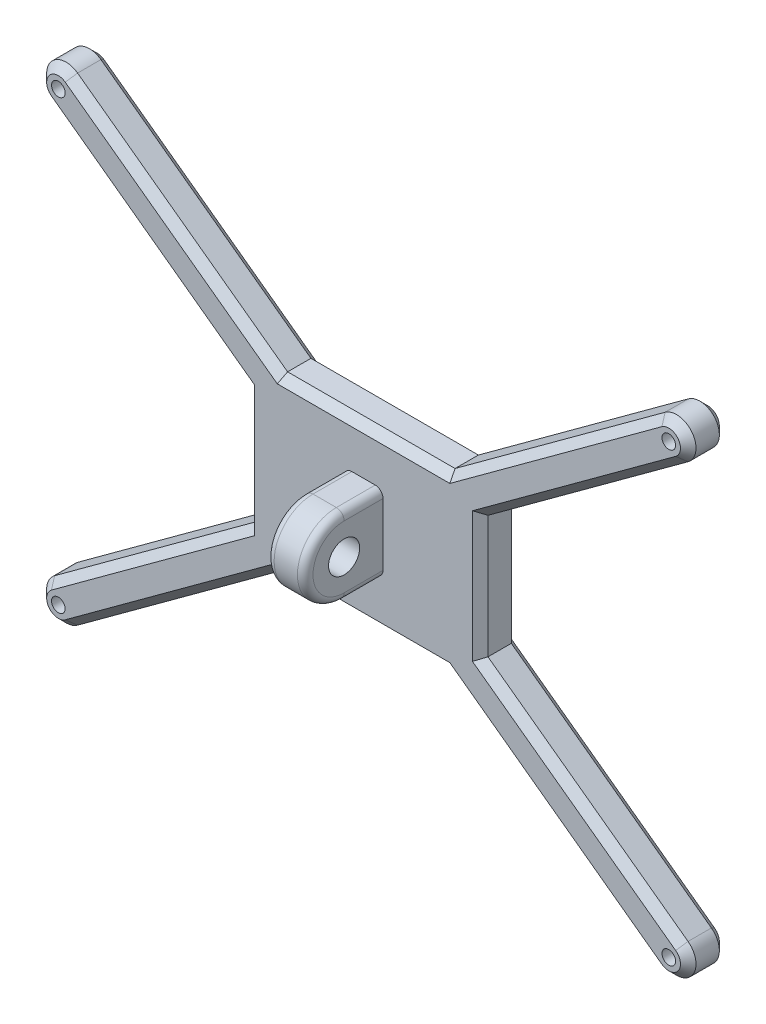
from build123d import *

# Parameters (mm, degrees)
ESQUISSE1_R        = 1.75
BOSS_EXTRU_1_DEPTH = 10
BOSS_EXTRU_2_START = 25
ESQUISSE2_R        = 4
BOSS_EXTRU_2_DEPTH = 10
CHANFREIN1_SIZE    = 2
CONG_1_R           = 2


with BuildPart() as part:
    # Esquisse1 → Boss.-Extru.1 (new body)
    with BuildSketch(Plane.XY):
        with BuildLine():
            Line((-2.952917385, 110.865117237), (48.5, 73.209447125))
            Line((48.5, 73.209447125), (48.5, 41.690552875))
            Line((48.5, 41.690552875), (-2.952917385, 4.034882763))
            ThreePointArc((-2.952917385, 4.034882763), (-4.034882763, -2.952917385), (2.952917385, -4.034882763))
            Line((2.952917385, -4.034882763), (56.966203668, 35.494585987))
            Line((56.966203668, 35.494585987), (100.033796332, 35.494585987))
            Line((100.033796332, 35.494585987), (154.047082615, -4.034882763))
            ThreePointArc((154.047082615, -4.034882763), (161.034882763, -2.952917385), (159.952917385, 4.034882763))
            Line((159.952917385, 4.034882763), (108.5, 41.690552875))
            Line((108.5, 41.690552875), (108.5, 73.209447125))
            Line((108.5, 73.209447125), (159.952917385, 110.865117237))
            ThreePointArc((159.952917385, 110.865117237), (161.034882763, 117.852917385), (154.047082615, 118.934882763))
            Line((154.047082615, 118.934882763), (100.033796332, 79.405414013))
            Line((100.033796332, 79.405414013), (56.966203668, 79.405414013))
            Line((56.966203668, 79.405414013), (2.952917385, 118.934882763))
            ThreePointArc((2.952917385, 118.934882763), (-4.034882763, 117.852917385), (-2.952917385, 110.865117237))
        make_face()
        Circle(ESQUISSE1_R, mode=Mode.SUBTRACT)
        with Locations((0, 114.9)):
            Circle(ESQUISSE1_R, mode=Mode.SUBTRACT)
        with Locations((157, 0)):
            Circle(ESQUISSE1_R, mode=Mode.SUBTRACT)
        with Locations((157, 114.9)):
            Circle(ESQUISSE1_R, mode=Mode.SUBTRACT)
    extrude(amount=BOSS_EXTRU_1_DEPTH)

    # Esquisse2 → Boss.-Extru.2 (add)
    with BuildSketch(Plane(origin=(48.5, 158.810828025, 0), x_dir=(0, 0, 1), z_dir=(1, 0, 0)).offset(BOSS_EXTRU_2_START)):
        with BuildLine():
            Line((10, 111.360828025), (20, 111.360828025))
            ThreePointArc((20, 111.360828025), (30, 101.360828025), (20, 91.360828025))
            Line((20, 91.360828025), (10, 91.360828025))
            Line((10, 91.360828025), (10, 111.360828025))
        make_face()
        with Locations((20, 101.360828025)):
            Circle(ESQUISSE2_R, mode=Mode.SUBTRACT)
    extrude(amount=BOSS_EXTRU_2_DEPTH)

    # Chanfrein1
    chanfrein1_edges = [part.edges().sort_by_distance(p)[0] for p in [
        (161.034882763, -2.952917385, 10),
        (127.040439473, 15.729851612, 10),
        (78.5, 35.494585987, 10),
        (29.959560527, 15.729851612, 10),
        (-4.034882763, -2.952917385, 10),
        (22.773541307, 22.862717819, 10),
        (48.5, 57.45, 10),
        (22.773541307, 92.037282181, 10),
        (-4.034882763, 117.852917385, 10),
        (29.959560527, 99.170148388, 10),
        (78.5, 79.405414013, 10),
        (127.040439473, 99.170148388, 10),
        (161.034882763, 117.852917385, 10),
        (134.226458693, 92.037282181, 10),
        (108.5, 57.45, 10),
        (134.226458693, 22.862717819, 10),
        (108.5, 57.45, 0),
        (134.226458693, 92.037282181, 0),
        (161.034882763, 117.852917385, 0),
        (127.040439473, 99.170148388, 0),
        (78.5, 79.405414013, 0),
        (29.959560527, 99.170148388, 0),
        (-4.034882763, 117.852917385, 0),
        (22.773541307, 92.037282181, 0),
        (48.5, 57.45, 0),
        (22.773541307, 22.862717819, 0),
        (-4.034882763, -2.952917385, 0),
        (29.959560527, 15.729851612, 0),
        (78.5, 35.494585987, 0),
        (127.040439473, 15.729851612, 0),
        (161.034882763, -2.952917385, 0),
        (134.226458693, 22.862717819, 0),
    ]]
    chamfer(chanfrein1_edges, length=CHANFREIN1_SIZE)

    # Congé1
    cong_1_edges = [part.edges().sort_by_distance(p)[0] for p in [
        (83.5, 67.45, 15),
        (83.5, 47.45, 15),
        (73.5, 67.45, 15),
        (73.5, 47.45, 15),
        (83.5, 57.45, 30),
        (73.5, 57.45, 30),
    ]]
    fillet(cong_1_edges, radius=CONG_1_R)


solid = part.part
